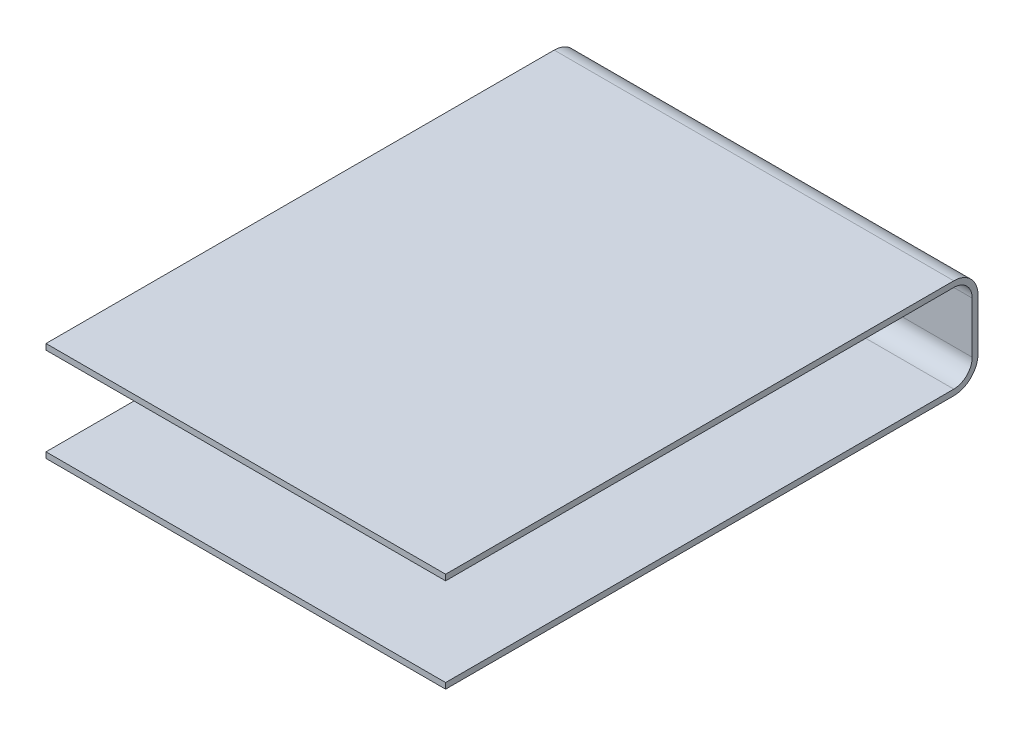
from build123d import *

# Parameters (mm, degrees)
BOSS_EXTRUDE1_DEPTH = 7590


with BuildPart() as part:
    # Sketch1 → Boss-Extrude1 (new body)
    with BuildSketch(Plane(origin=(0, 0, 0), x_dir=(0, 0, -1), z_dir=(1, 0, 0))):
        with BuildLine():
            Line((0, 0), (-9652, 0))
            Line((-9652, 0), (-9652, -110))
            Line((-9652, -110), (0, -110))
            ThreePointArc((0, -110), (325.269119346, 24.730880654), (460, 350))
            Line((460, 350), (460, 1322))
            ThreePointArc((460, 1322), (325.269119346, 1647.269119346), (0, 1782))
            Line((0, 1782), (-9652, 1782))
            Line((-9652, 1782), (-9652, 1672))
            Line((-9652, 1672), (0, 1672))
            ThreePointArc((0, 1672), (247.487373415, 1569.487373415), (350, 1322))
            Line((350, 1322), (350, 350))
            ThreePointArc((350, 350), (247.487373415, 102.512626585), (0, 0))
        make_face()
    extrude(amount=-BOSS_EXTRUDE1_DEPTH)


solid = part.part
